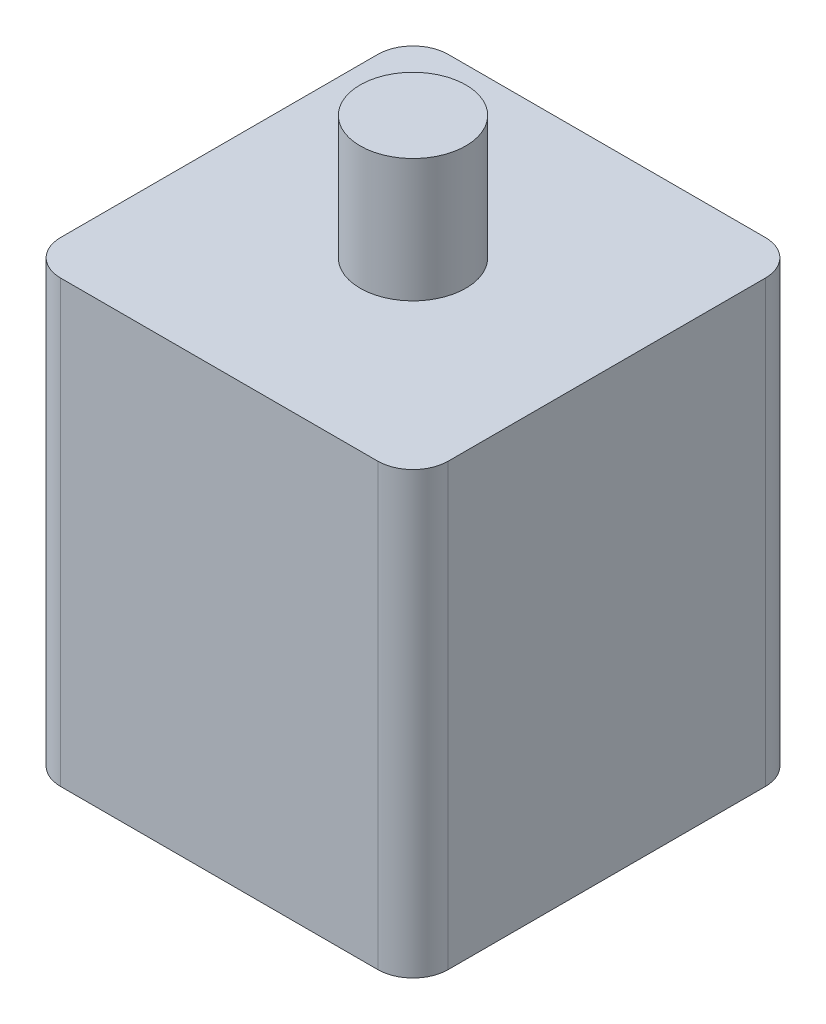
from build123d import *

# Parameters (mm, degrees)
SKETCH1_R           = 6
BOSS_EXTRUDE1_DEPTH = 25
SKETCH2_R           = 3
BOSS_EXTRUDE2_DEPTH = 7


with BuildPart() as part:
    # Sketch1 → Boss-Extrude1 (new body)
    with BuildSketch(Plane(origin=(0, 0, 0), x_dir=(1, 0, 0), z_dir=(0, 1, 0))):
        with BuildLine():
            ThreePointArc((-11, 9), (-10.414213562, 10.414213562), (-9, 11))
            Line((-9, 11), (9, 11))
            ThreePointArc((9, 11), (10.414213562, 10.414213562), (11, 9))
            Line((11, 9), (11, -9))
            ThreePointArc((11, -9), (10.414213562, -10.414213562), (9, -11))
            Line((9, -11), (-9, -11))
            ThreePointArc((-9, -11), (-10.414213562, -10.414213562), (-11, -9))
            Line((-11, -9), (-11, 9))
        make_face()
        Circle(SKETCH1_R, mode=Mode.SUBTRACT)
        Circle(SKETCH1_R)
    extrude(amount=BOSS_EXTRUDE1_DEPTH)

    # Sketch2 → Boss-Extrude2 (add)
    with BuildSketch(Plane(origin=(0, 25, 0), x_dir=(1, 0, 0), z_dir=(0, 1, 0))):
        with Locations(Location((0, 0, 0), (0, 0, 270))):
            Circle(SKETCH2_R)
    extrude(amount=BOSS_EXTRUDE2_DEPTH)


solid = part.part
